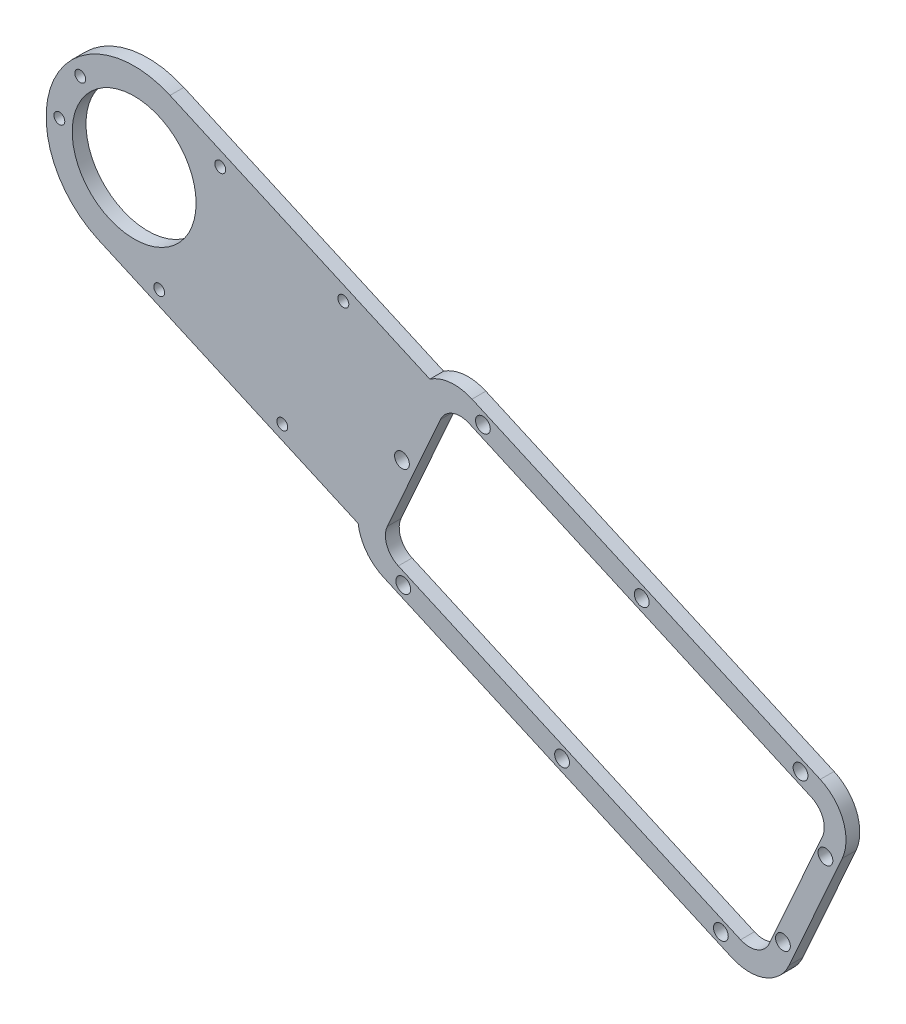
from build123d import *

# Parameters (mm, degrees)
SKETCH1_R           = 14.25
SKETCH1_R_2         = 1.7
BOSS_EXTRUDE1_DEPTH = 3.175
SKETCH5_R           = 1.25
CUT_EXTRUDE4_DEPTH  = 4.175
CUT_EXTRUDE5_DEPTH  = 10
FILLET1_R           = 5
FILLET2_R           = 5


with BuildPart() as part:
    # Sketch1 → Boss-Extrude1 (new body)
    with BuildSketch(Plane.XY):
        with BuildLine():
            Line((-72.715301765, 90.837326721), (-152.817002247, 126.544575004))
            ThreePointArc((-152.817002247, 126.544575004), (-157.784388135, 127.370762315), (-162.524605276, 125.671394934))
            Line((-162.524605276, 125.671394934), (-222.299360222, 152.317421212))
            ThreePointArc((-222.299360222, 152.317421212), (-249.039738928, 142.066706765), (-238.78902448, 115.326328059))
            Line((-238.78902448, 115.326328059), (-179.014269534, 88.680301782))
            ThreePointArc((-179.014269534, 88.680301782), (-177.109561802, 84.018800254), (-173.174612442, 80.876558766))
            Line((-173.174612442, 80.876558766), (-93.072911961, 45.169310483))
            ThreePointArc((-93.072911961, 45.169310483), (-85.421957972, 44.965480094), (-79.867786674, 50.231391692))
            Line((-79.867786674, 50.231391692), (-67.653220557, 77.632201435))
            ThreePointArc((-67.653220557, 77.632201435), (-67.449390168, 85.283155423), (-72.715301765, 90.837326721))
        make_face()
        with Locations((-230.544192351, 133.821874636)):
            Circle(SKETCH1_R, mode=Mode.SUBTRACT)
        with Locations((-95.571468701, 49.02024728)):
            Circle(SKETCH1_R_2, mode=Mode.SUBTRACT)
        with Locations((-132.105881692, 65.306335437)):
            Circle(SKETCH1_R_2, mode=Mode.SUBTRACT)
        with Locations((-168.640294682, 81.592423593)):
            Circle(SKETCH1_R_2, mode=Mode.SUBTRACT)
        with Locations((-150.318445506, 122.693638207)):
            Circle(SKETCH1_R_2, mode=Mode.SUBTRACT)
        with Locations((-113.784032516, 106.407550051)):
            Circle(SKETCH1_R_2, mode=Mode.SUBTRACT)
        with Locations((-77.249619525, 90.121461895)):
            Circle(SKETCH1_R_2, mode=Mode.SUBTRACT)
        with Locations((-81.295075004, 54.152214057)):
            Circle(SKETCH1_R_2, mode=Mode.SUBTRACT)
        with Locations((-71.52342211, 76.072861852)):
            Circle(SKETCH1_R_2, mode=Mode.SUBTRACT)
        with Locations((-168.932649456, 106.357056211)):
            Circle(SKETCH1_R_2, mode=Mode.SUBTRACT)
    extrude(amount=BOSS_EXTRUDE1_DEPTH)

    # Sketch5 → Cut-Extrude4 (cut, through all)
    with BuildSketch(Plane.XY.offset(3.175)):
        with Locations((-196.466353254, 99.744559857)):
            Circle(SKETCH5_R)
        with Locations((-224.780523322, 112.366278179)):
            Circle(SKETCH5_R)
        with Locations((-210.733772287, 143.877209383)):
            Circle(SKETCH5_R)
        with Locations((-182.419602219, 131.255491062)):
            Circle(SKETCH5_R)
        with Locations((-242.947351213, 145.810375386)):
            Circle(SKETCH5_R)
        with Locations((-247.751623016, 135.033002179)):
            Circle(SKETCH5_R)
    extrude(amount=-CUT_EXTRUDE4_DEPTH, mode=Mode.SUBTRACT)

    # Sketch6 → Cut-Extrude5 (cut)
    with BuildSketch(Plane.XY.offset(3.175)):
        Polygon((-158.059591703, 123.407293834), (-70.184261161, 84.234764078), (-86.470349317, 47.700351088), (-174.345679859, 86.872880843), align=None)
    extrude(amount=-CUT_EXTRUDE5_DEPTH, mode=Mode.SUBTRACT)

    # Fillet1
    fillet1_edges = [part.edges().sort_by_distance(p)[0] for p in [
        (-174.345679859, 86.872880843, 1.5875),
        (-158.059591703, 123.407293834, 1.5875),
    ]]
    fillet(fillet1_edges, radius=FILLET1_R)

    # Fillet2
    fillet2_edges = [part.edges().sort_by_distance(p)[0] for p in [
        (-70.184261161, 84.234764078, 1.5875),
        (-86.470349317, 47.700351088, 1.5875),
    ]]
    fillet(fillet2_edges, radius=FILLET2_R)


solid = part.part
